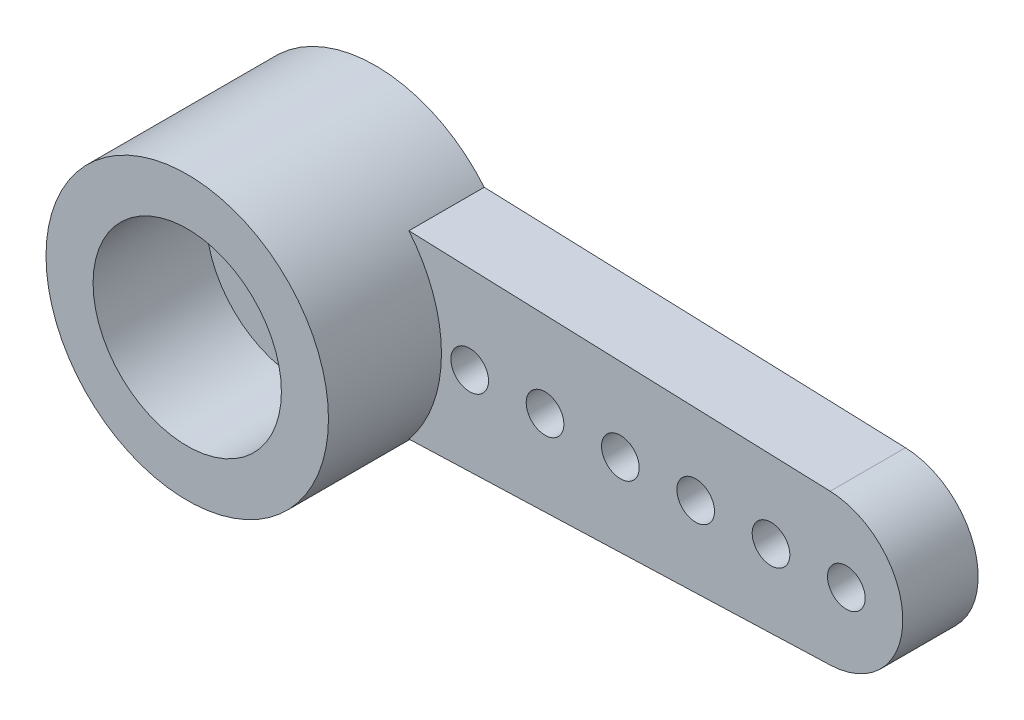
from build123d import *

# Parameters (mm, degrees)
EXTRUDE_3_DEPTH     = 2
EXTRUDE_3_2_DEPTH   = 2
SKETCH_2_R          = 3.75
SKETCH_2_R_2        = 2.5
EXTRUDE_5_DEPTH     = 3
SKETCH_3_R          = 3.75
SKETCH_3_R_2        = 2.5
EXTRUDE_6_DEPTH     = 2
SKETCH_4_R          = 0.5
CUT_EXTRUDE_1_DEPTH = 2
SKETCH_5_R          = 2.5
EXTRUDE_7_DEPTH     = 1
SKETCH_6_R          = 2.5
CUT_EXTRUDE_2_DEPTH = 0.5
SKETCH_7_R          = 1.25
CUT_EXTRUDE_3_DEPTH = 5


with BuildPart() as part:
    # Эскиз1 → Бобышка-Вытянуть3 (new body)
    with BuildSketch(Plane.XY):
        with BuildLine():
            ThreePointArc((-0.233236, 2.489096416), (-1.84838984, 1.683286963), (-2.5, 0))
            ThreePointArc((-2.5, 0), (-1.84838984, -1.683286963), (-0.233236, -2.489096416))
            Line((-0.233236, -2.489096416), (0, -2.497361401))
            Line((0, -2.497361401), (0.233236, -2.489096416))
            ThreePointArc((0.233236, -2.489096416), (2.5, 0), (0.233236, 2.489096416))
            Line((0.233236, 2.489096416), (0, 2.497361401))
            Line((0, 2.497361401), (-0.233236, 2.489096416))
        make_face()
    extrude(amount=EXTRUDE_3_DEPTH)



with BuildPart() as body_2:
    # Эскиз1 → Extrude 3 2 (new body)
    with BuildSketch(Plane.XY):
        with BuildLine():
            Line((14.07082784, 1.998745461), (2.88547071, 2.395111434))
            ThreePointArc((2.88547071, 2.395111434), (3.75, 0), (2.88547071, -2.395111434))
            Line((2.88547071, -2.395111434), (14.07082784, -1.998745461))
            ThreePointArc((14.07082784, -1.998745461), (16, 0), (14.07082784, 1.998745461))
        make_face()
    extrude(amount=EXTRUDE_3_2_DEPTH)


with BuildPart() as body_3:
    # Эскиз2 → Бобышка-Вытянуть5 (new body)
    with BuildSketch(Plane.XY.offset(2)):
        Circle(SKETCH_2_R)
        Circle(SKETCH_2_R_2, mode=Mode.SUBTRACT)
    extrude(amount=EXTRUDE_5_DEPTH)


with BuildPart() as part_1:
    add(part.part)

    add(body_2.part)  # Бобышка-Вытянуть6 merges body 2

    add(body_3.part)  # Бобышка-Вытянуть6 merges body 3
    # Эскиз3 → Бобышка-Вытянуть6 (add)
    with BuildSketch(Plane(origin=(0, 0, 2), x_dir=(-1, 0, 0), z_dir=(0, 0, -1))):
        Circle(SKETCH_3_R)
        Circle(SKETCH_3_R_2, mode=Mode.SUBTRACT)
    extrude(amount=EXTRUDE_6_DEPTH)

    # Эскиз4 → Вырез-Вытянуть1 (cut)
    with BuildSketch(Plane(origin=(0, 0, 0), x_dir=(-1, 0, 0), z_dir=(0, 0, -1))):
        with Locations((-14.5, 0)):
            Circle(SKETCH_4_R)
        with Locations((-4.5, 0)):
            Circle(SKETCH_4_R)
        with Locations((-6.5, 0)):
            Circle(SKETCH_4_R)
        with Locations((-8.5, 0)):
            Circle(SKETCH_4_R)
        with Locations((-10.5, 0)):
            Circle(SKETCH_4_R)
        with Locations((-12.5, 0)):
            Circle(SKETCH_4_R)
    extrude(amount=-CUT_EXTRUDE_1_DEPTH, mode=Mode.SUBTRACT)

    # Эскиз5 → Бобышка-Вытянуть7 (add)
    with BuildSketch(Plane(origin=(0, 0, 0), x_dir=(-1, 0, 0), z_dir=(0, 0, -1))):
        Circle(SKETCH_5_R)
    extrude(amount=-EXTRUDE_7_DEPTH)

    # Эскиз6 → Вырез-Вытянуть2 (cut)
    with BuildSketch(Plane(origin=(0, 0, 0), x_dir=(-1, 0, 0), z_dir=(0, 0, -1))):
        Circle(SKETCH_6_R)
    extrude(amount=-CUT_EXTRUDE_2_DEPTH, mode=Mode.SUBTRACT)

    # Эскиз7 → Вырез-Вытянуть3 (cut)
    with BuildSketch(Plane(origin=(0, 0, 0.5), x_dir=(-1, 0, 0), z_dir=(0, 0, -1))):
        Circle(SKETCH_7_R)
    extrude(amount=-CUT_EXTRUDE_3_DEPTH, mode=Mode.SUBTRACT)


solid = part_1.part
